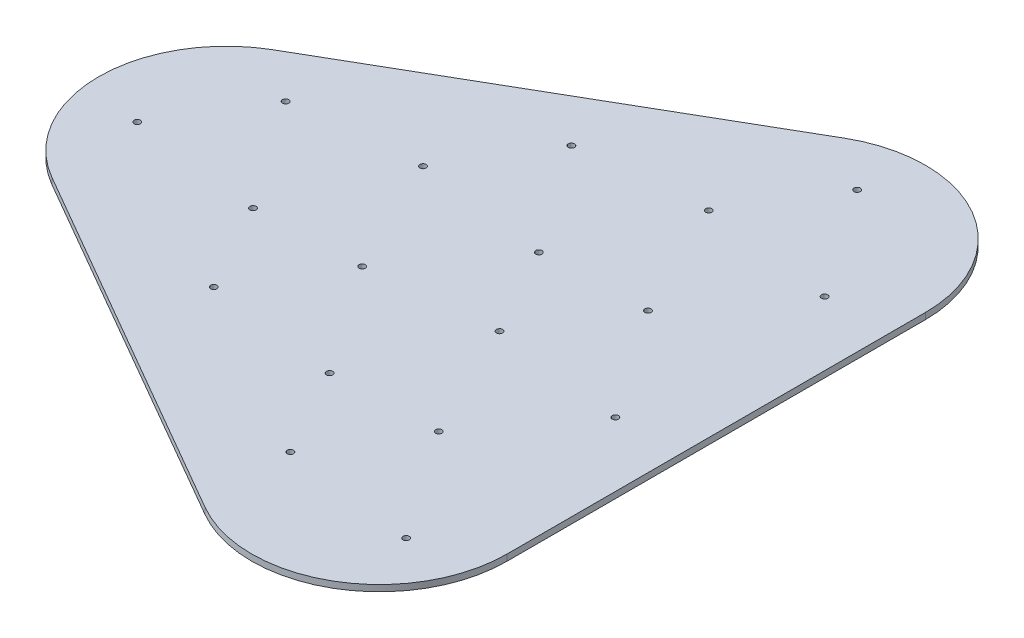
from build123d import *

# Parameters (mm, degrees)
SKETCH1_R           = 1.5
BOSS_EXTRUDE1_DEPTH = 3


with BuildPart() as part:
    # Sketch1 → Boss-Extrude1 (new body)
    with BuildSketch(Plane(origin=(0, 0, 0), x_dir=(1, 0, 0), z_dir=(0, 1, 0))):
        with BuildLine():
            Line((234.205080757, -100), (234.205080757, 100))
            ThreePointArc((234.205080757, 100), (203.705080757, 152.827549631), (142.705080757, 152.827549631))
            Line((142.705080757, 152.827549631), (-30.5, 52.827549631))
            ThreePointArc((-30.5, 52.827549631), (-61, 0), (-30.5, -52.827549631))
            Line((-30.5, -52.827549631), (142.705080757, -152.827549631))
            ThreePointArc((142.705080757, -152.827549631), (203.705080757, -152.827549631), (234.205080757, -100))
        make_face()
        with Locations((53.582540378, -59.525)):
            Circle(SKETCH1_R, mode=Mode.SUBTRACT)
        with Locations((80.524854378, -15.531728)):
            Circle(SKETCH1_R, mode=Mode.SUBTRACT)
        with Locations((116.913429378, -67.500001)):
            Circle(SKETCH1_R, mode=Mode.SUBTRACT)
        with Locations((53.582540378, 40.475)):
            Circle(SKETCH1_R, mode=Mode.SUBTRACT)
        with Locations((80.524854378, 84.468272)):
            Circle(SKETCH1_R, mode=Mode.SUBTRACT)
        with Locations((116.913429378, 32.499999)):
            Circle(SKETCH1_R, mode=Mode.SUBTRACT)
        with Locations((203.515969757, -17.500001)):
            Circle(SKETCH1_R, mode=Mode.SUBTRACT)
        with Locations((140.185080757, -9.525)):
            Circle(SKETCH1_R, mode=Mode.SUBTRACT)
        with Locations((167.127394757, 34.468272)):
            Circle(SKETCH1_R, mode=Mode.SUBTRACT)
        with Locations((-6.077686, 34.468272)):
            Circle(SKETCH1_R, mode=Mode.SUBTRACT)
        with Locations((-33.02, -9.525)):
            Circle(SKETCH1_R, mode=Mode.SUBTRACT)
        with Locations((30.310889, -17.500001)):
            Circle(SKETCH1_R, mode=Mode.SUBTRACT)
        with Locations((167.127394757, 134.468272)):
            Circle(SKETCH1_R, mode=Mode.SUBTRACT)
        with Locations((140.185080757, 90.475)):
            Circle(SKETCH1_R, mode=Mode.SUBTRACT)
        with Locations((203.515969757, 82.499999)):
            Circle(SKETCH1_R, mode=Mode.SUBTRACT)
        with Locations((167.127394757, -65.531728)):
            Circle(SKETCH1_R, mode=Mode.SUBTRACT)
        with Locations((140.185080757, -109.525)):
            Circle(SKETCH1_R, mode=Mode.SUBTRACT)
        with Locations((203.515969757, -117.500001)):
            Circle(SKETCH1_R, mode=Mode.SUBTRACT)
    extrude(amount=BOSS_EXTRUDE1_DEPTH)


solid = part.part
